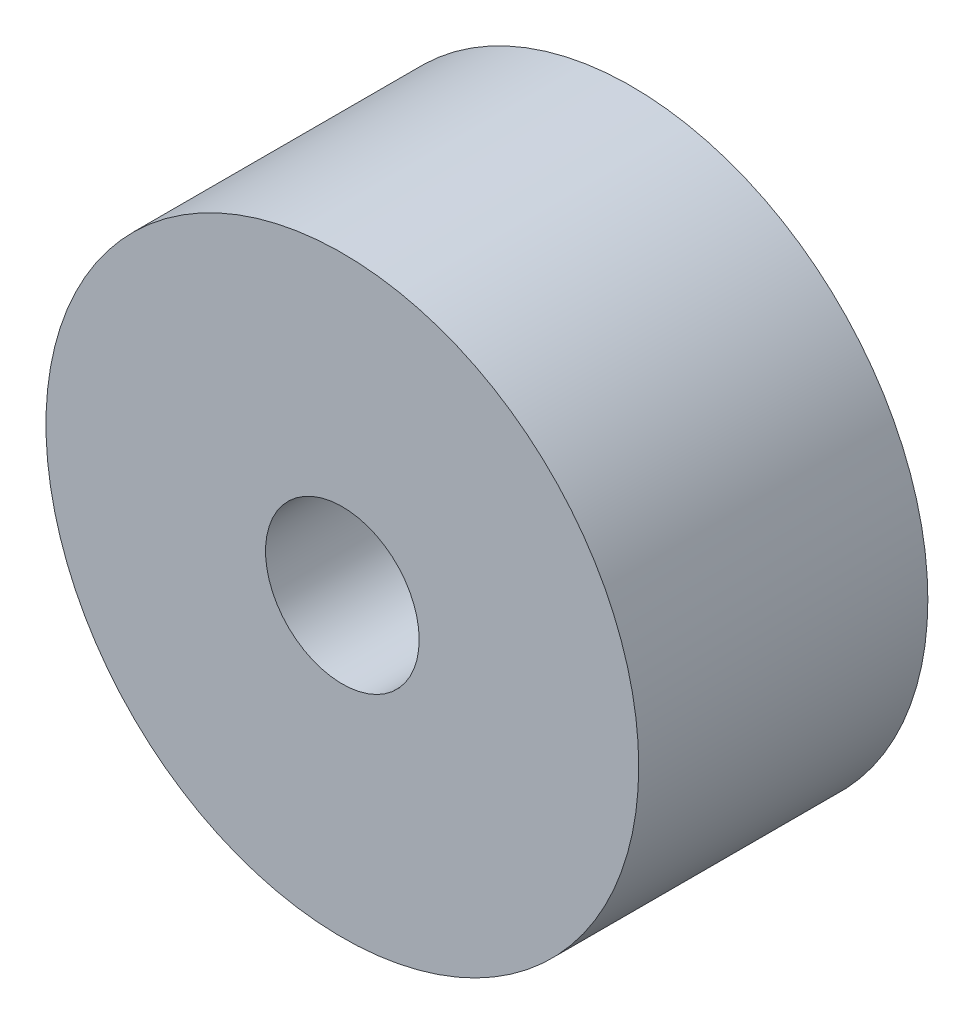
from build123d import *

# Parameters (mm, degrees)
SKETCH_1_R          = 24.5
EXTRUDE_1_DEPTH     = 23.9
SKETCH_2_R          = 6.35
CUT_EXTRUDE_1_DEPTH = 10


with BuildPart() as part:
    # 草图1 → 凸台-拉伸1 (new body)
    with BuildSketch(Plane.XY):
        Circle(SKETCH_1_R)
    extrude(amount=EXTRUDE_1_DEPTH)

    # 草图2 → 切除-拉伸1 (cut)
    with BuildSketch(Plane.XY.offset(23.9)):
        Circle(SKETCH_2_R)
    extrude(amount=-CUT_EXTRUDE_1_DEPTH, mode=Mode.SUBTRACT)


solid = part.part
